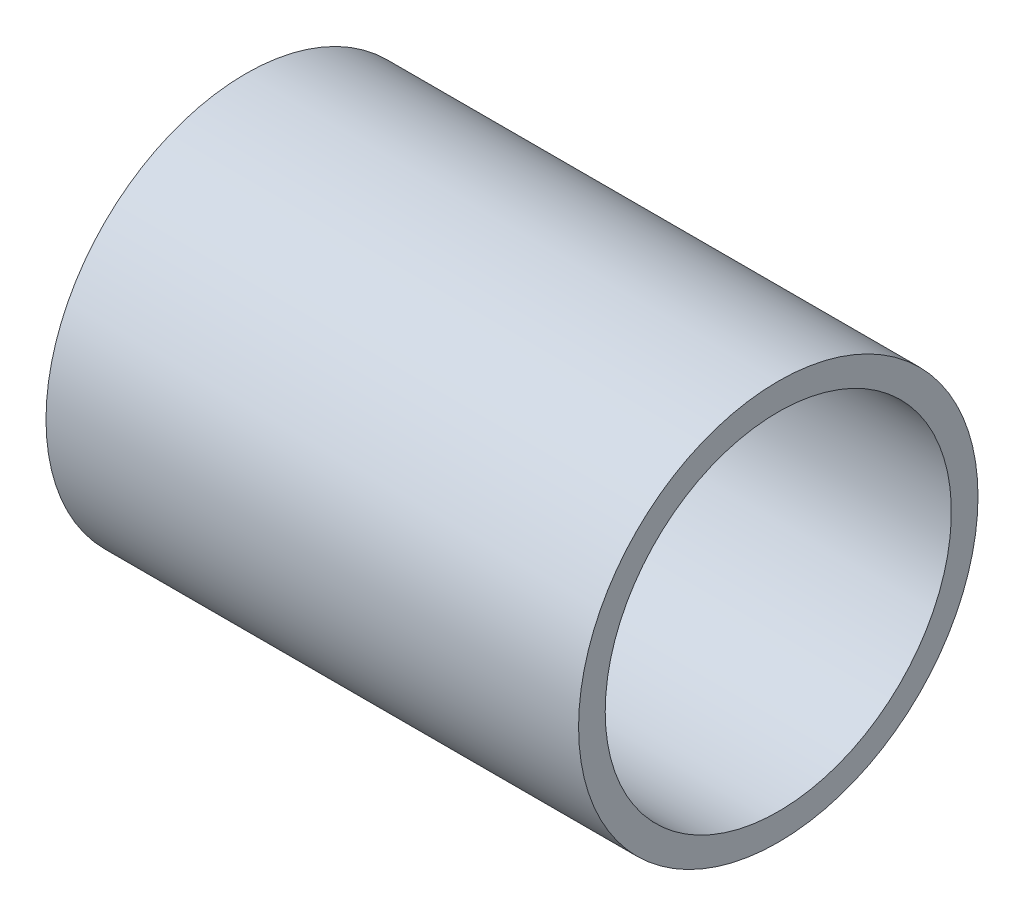
from build123d import *

# Parameters (mm, degrees)
SKETCH1_W = 254
SKETCH1_H = 12.7


with BuildPart() as part:
    # Sketch1 → Revolve-Thin2 (revolve)
    with BuildSketch(Plane(origin=(0, 0, 0), x_dir=(1, 0, 0), z_dir=(0, 1, 0))):
        with Locations((127, -88.9)):
            Rectangle(SKETCH1_W, SKETCH1_H)
    revolve(axis=Axis((0, 0, 0), (1, 0, 0)))


solid = part.part
